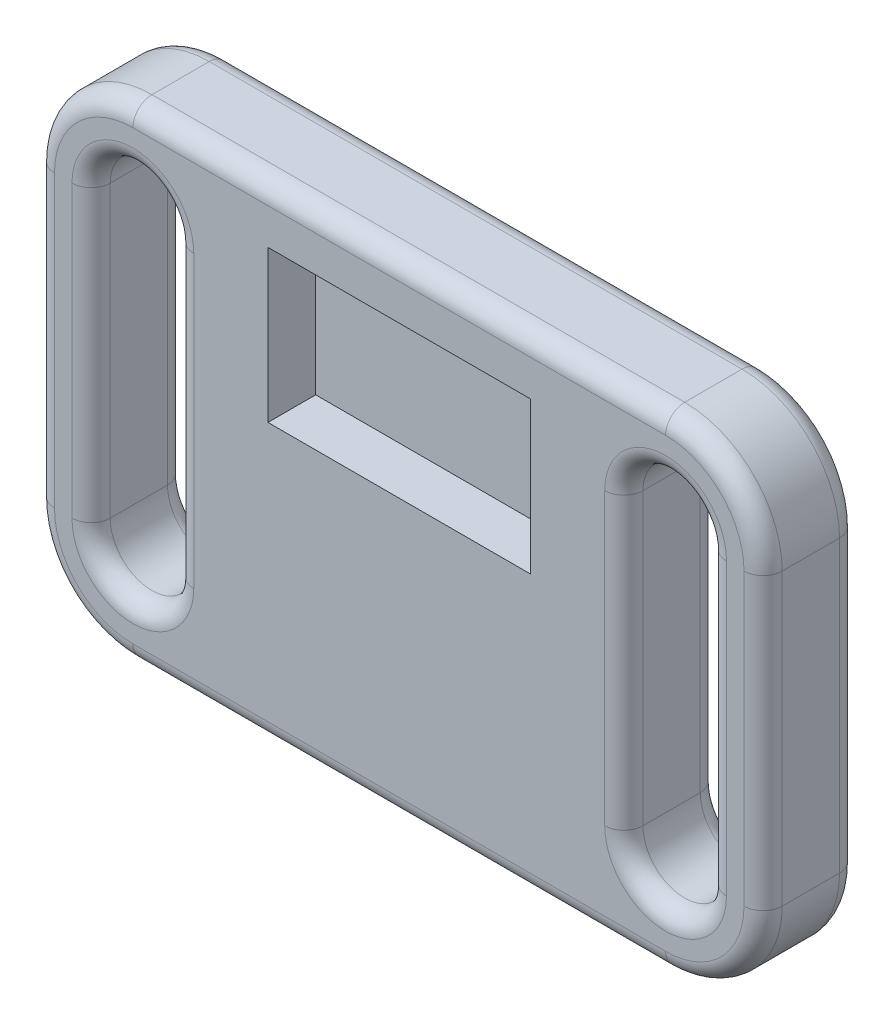
from build123d import *

# Parameters (mm, degrees)
STEERING_WHEEL_BODY_DEPTH = 20
FILLET1_R                 = 8
LCD_START                 = 20
SKETCH3_W                 = 109.98522628
SKETCH3_H                 = 63.5
LCD_CUTOUT_DEPTH          = 20
CIRPATTERN1_COUNT         = 9


with BuildPart() as part:
    # Sketch1 → Steering Wheel Body (new body, symmetric)
    with BuildSketch(Plane.XY):
        with BuildLine():
            Line((-152.4, -60.766666667), (-152.4, 60.766666667))
            ThreePointArc((-152.4, 60.766666667), (-140.440193565, 89.640193565), (-111.566666667, 101.6))
            Line((-111.566666667, 101.6), (111.566666667, 101.6))
            ThreePointArc((111.566666667, 101.6), (140.440193565, 89.640193565), (152.4, 60.766666667))
            Line((152.4, 60.766666667), (152.4, -60.766666667))
            ThreePointArc((152.4, -60.766666667), (140.440193565, -89.640193565), (111.566666667, -101.6))
            Line((111.566666667, -101.6), (-111.566666667, -101.6))
            ThreePointArc((-111.566666667, -101.6), (-140.440193565, -89.640193565), (-152.4, -60.766666667))
        make_face()
        with BuildLine():
            Line((-129.066666667, 60.766666667), (-129.066666667, -60.766666667))
            ThreePointArc((-129.066666667, -60.766666667), (-111.566666667, -78.266666667), (-94.066666667, -60.766666667))
            Line((-94.066666667, -60.766666667), (-94.066666667, 60.766666667))
            ThreePointArc((-94.066666667, 60.766666667), (-111.566666667, 78.266666667), (-129.066666667, 60.766666667))
        make_face(mode=Mode.SUBTRACT)
        with BuildLine():
            Line((129.066666667, 60.766666667), (129.066666667, -60.766666667))
            ThreePointArc((129.066666667, -60.766666667), (111.566666667, -78.266666667), (94.066666667, -60.766666667))
            Line((94.066666667, -60.766666667), (94.066666667, 60.766666667))
            ThreePointArc((94.066666667, 60.766666667), (111.566666667, 78.266666667), (129.066666667, 60.766666667))
        make_face(mode=Mode.SUBTRACT)
    extrude(amount=STEERING_WHEEL_BODY_DEPTH, both=True)

    # Fillet1
    fillet1_edges = [part.edges().sort_by_distance(p)[0] for p in [
        (0, -101.6, -20),
        (-140.440193565, -89.640193565, -20),
        (-152.4, 0, -20),
        (-140.440193565, 89.640193565, -20),
        (-140.440193565, -89.640193565, 20),
        (0, -101.6, 20),
        (140.440193565, -89.640193565, 20),
        (-111.566666667, 78.266666667, -20),
        (-129.066666667, 0, -20),
        (152.4, 0, 20),
        (-111.566666667, -78.266666667, -20),
        (-94.066666667, 0, -20),
        (-111.566666667, 78.266666667, 20),
        (-129.066666667, 0, 20),
        (-111.566666667, -78.266666667, 20),
        (-94.066666667, 0, 20),
        (140.440193565, 89.640193565, 20),
        (0, 101.6, 20),
        (111.566666667, -78.266666667, -20),
        (129.066666667, 0, -20),
        (111.566666667, 78.266666667, -20),
        (94.066666667, 0, -20),
        (111.566666667, -78.266666667, 20),
        (129.066666667, 0, 20),
        (111.566666667, 78.266666667, 20),
        (94.066666667, 0, 20),
        (-140.440193565, 89.640193565, 20),
        (0, 101.6, -20),
        (-152.4, 0, 20),
        (140.440193565, 89.640193565, -20),
        (152.4, 0, -20),
        (140.440193565, -89.640193565, -20),
    ]]
    fillet(fillet1_edges, radius=FILLET1_R)

    # Sketch3 → LCD Cutout (cut)
    with BuildSketch(Plane.XY.offset(LCD_START)):
        with Locations((0, 46.75)):
            Rectangle(SKETCH3_W, SKETCH3_H)
    extrude(amount=-LCD_CUTOUT_DEPTH, mode=Mode.SUBTRACT)

    # Sketch7 → M5x0.8 Tapped Hole1 (revolve, cut)
    with BuildSketch(Plane(origin=(0, 41.96005, -20), x_dir=(0, 1, 0), z_dir=(1, 0, 0))):
        Polygon((0, 0), (0, 9.6618073), (2.1, 8.4), (2.1, 0), align=None)
    m5x0_8_tapped_hole1 = revolve(axis=Axis((0, 41.96005, -26.35), (0, 0, 1)), mode=Mode.SUBTRACT)

    # CirPattern1: M5x0.8 Tapped Hole1 ×9 about axis
    cirpattern1_axis = Axis((0, 0, 0), (0, 0, 1))
    for i in range(1, CIRPATTERN1_COUNT):
        add(m5x0_8_tapped_hole1.rotate(cirpattern1_axis, i * 360 / CIRPATTERN1_COUNT), mode=Mode.SUBTRACT)


solid = part.part
